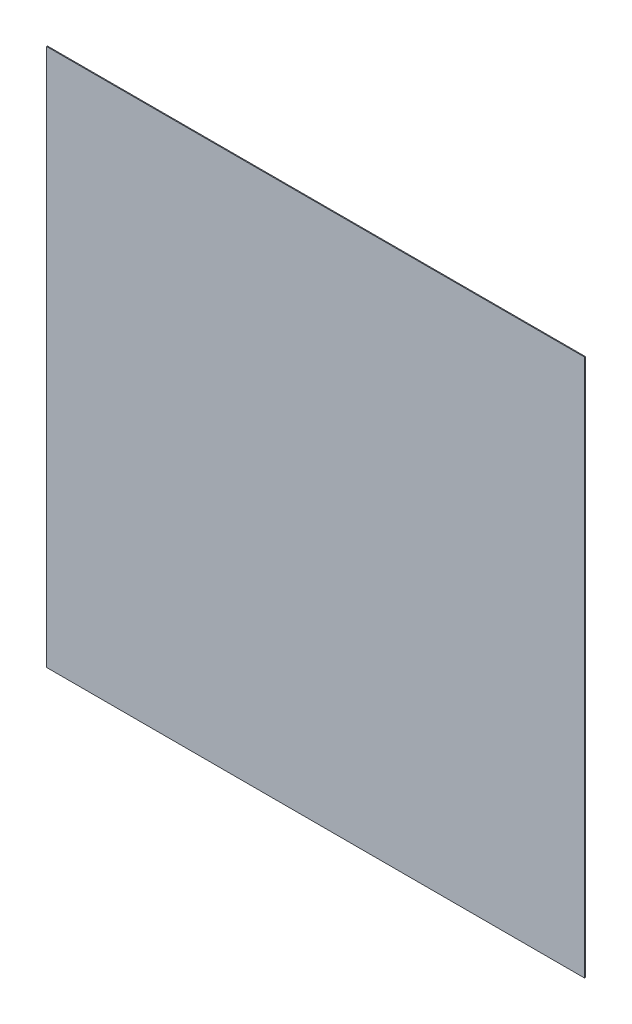
from build123d import *

# Parameters (mm, degrees)
SKETCH3_W                = 304.8
SKETCH3_H                = 304.8
BOSS_EXTRUDE1_DEPTH      = 0.254
BOSS_EXTRUDE1_DEPTH_BACK = 0.254


with BuildPart() as part:
    # Sketch3 → Boss-Extrude1 (new body, two sides)
    with BuildSketch(Plane.XY) as boss_extrude1_sk:
        Rectangle(SKETCH3_W, SKETCH3_H)
    extrude(amount=BOSS_EXTRUDE1_DEPTH)
    extrude(boss_extrude1_sk.sketch, amount=-BOSS_EXTRUDE1_DEPTH_BACK)


solid = part.part
